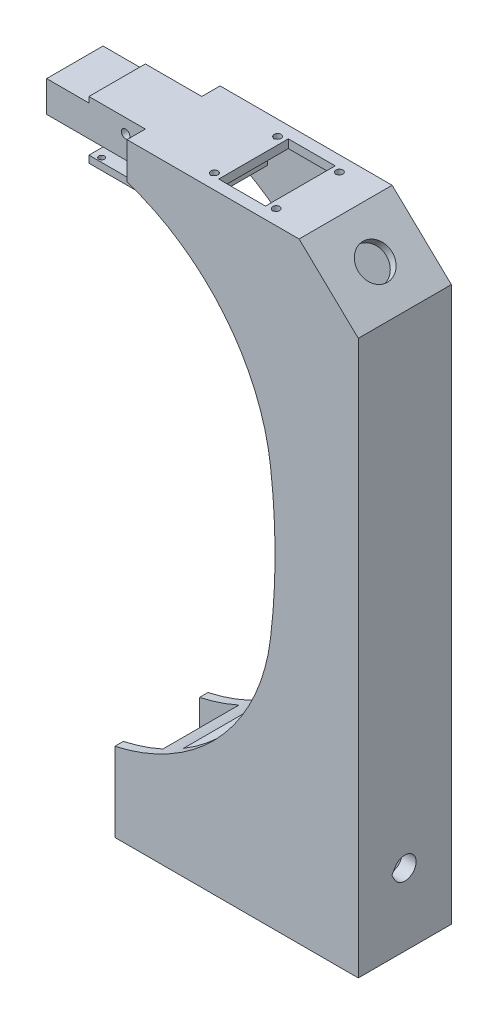
from build123d import *

# Parameters (mm, degrees)
EXTRUDE_6_DEPTH      = 33
CUT_EXTRUDE_START    = 3
CUT_EXTRUDE_2_DEPTH  = 27
EXTRUDE_START        = 6.5
SKETCH_7_W           = 35
SKETCH_7_H           = 13
EXTRUDE_7_DEPTH      = 20
EXTRUDE_START_2      = 1.5
SKETCH_11_W          = 17
SKETCH_11_H          = 2.5
EXTRUDE_15_DEPTH     = 30
CUT_EXTRUDE_START_2  = 180
CUT_EXTRUDE_3_DEPTH  = 10
SKETCH_13_R          = 1.5
CUT_EXTRUDE_4_DEPTH  = 30
SKETCH_14_W          = 15
SKETCH_14_H          = 2
CUT_EXTRUDE_5_DEPTH  = 30
EXTRUDE_START_3      = 11.5
SKETCH_15_W          = 67.299618531
SKETCH_15_H          = 10
EXTRUDE_16_DEPTH     = 10
CUT_EXTRUDE_START_3  = 17
CUT_EXTRUDE_7_DEPTH  = 75
CUT_EXTRUDE_START_4  = 13
CUT_EXTRUDE_9_DEPTH  = 5
SKETCH_20_W          = 16.6
SKETCH_20_H          = 24.7
CUT_EXTRUDE_10_DEPTH = 5
SKETCH_21_R          = 6
CUT_EXTRUDE_11_DEPTH = 5
SKETCH_22_W          = 51
SKETCH_22_H          = 47
CUT_EXTRUDE_12_DEPTH = 27


with BuildPart() as part:
    # Эскиз1 → Бобышка-Вытянуть6 (new body)
    with BuildSketch(Plane.XY):
        with BuildLine():
            Line((4.299618531, 175.402841826), (4.299618531, 188.402841826))
            Line((4.299618531, 188.402841826), (65.299618531, 188.402841826))
            Line((65.299618531, 188.402841826), (86.299618531, 168.402841826))
            Line((86.299618531, 168.402841826), (86.299619, 0))
            Line((86.299619, 0), (86.299619, -28))
            Line((86.299619, -28), (0, -28))
            Line((0, -28), (0, 0))
            ThreePointArc((0, 0), (37.229295141, 21.561020186), (55.173142182, 60.662380285))
            ThreePointArc((55.173142182, 60.662380285), (56.797307883, 87.162380285), (55.173142182, 113.662380285))
            ThreePointArc((55.173142182, 113.662380285), (38.726552267, 151.940422917), (4.299618531, 175.402841826))
        make_face()
    extrude(amount=EXTRUDE_6_DEPTH)

    # Эскиз5 → Вырез-Вытянуть2 (cut)
    with BuildSketch(Plane.XY.offset(CUT_EXTRUDE_START)):
        Polygon((24.099618531, 175.402841826), (4.299618531, 175.402841826), (4.299618531, 169.136823089), (-18.700381469, 169.136823089), (-18.700381469, -23.02337805), (14, -23.02337805), (14, 8.47662195), (81.178938205, 8.47662195), (81.178938205, 169.136823089), (64.099618531, 185.402841826), (24.099618531, 185.402841826), align=None)
    extrude(amount=CUT_EXTRUDE_2_DEPTH, mode=Mode.SUBTRACT)

    # Эскиз7 → Бобышка-Вытянуть7 (add)
    with BuildSketch(Plane.XY.offset(EXTRUDE_START)):
        with Locations((-13.200381469, 181.902841826)):
            Rectangle(SKETCH_7_W, SKETCH_7_H)
    extrude(amount=EXTRUDE_7_DEPTH)

    # Эскиз11 → Бобышка-Вытянуть15 (add)
    with BuildSketch(Plane.XY.offset(EXTRUDE_START_2)):
        with Locations((-2.200381469, 174.152841826)):
            Rectangle(SKETCH_11_W, SKETCH_11_H)
    extrude(amount=EXTRUDE_15_DEPTH)

    # Эскиз12 → Вырез-Вытянуть3 (cut)
    with BuildSketch(Plane(origin=(0, 0, 0), x_dir=(1, 0, 0), z_dir=(0, 1, 0)).offset(CUT_EXTRUDE_START_2)):
        with BuildLine():
            Line((-7.700381469, -31.154700538), (-7.200381469, -30.866025404))
            ThreePointArc((-7.200381469, -30.866025404), (-7.700381469, -29), (-8.200381469, -30.866025404))
            Line((-8.200381469, -30.866025404), (-7.700381469, -31.154700538))
        make_face()
        with BuildLine():
            Line((-7.700381469, -4.154700538), (-7.200381469, -3.866025404))
            ThreePointArc((-7.200381469, -3.866025404), (-7.700381469, -2), (-8.200381469, -3.866025404))
            Line((-8.200381469, -3.866025404), (-7.700381469, -4.154700538))
        make_face()
    extrude(amount=-CUT_EXTRUDE_3_DEPTH, mode=Mode.SUBTRACT)

    # Эскиз13 → Вырез-Вытянуть4 (cut)
    with BuildSketch(Plane.XY):
        with Locations((-2.700381469, 183.402841826)):
            Circle(SKETCH_13_R)
    extrude(amount=CUT_EXTRUDE_4_DEPTH, mode=Mode.SUBTRACT)

    # Эскиз14 → Вырез-Вытянуть5 (cut)
    with BuildSketch(Plane.XY):
        with Locations((-23.200381469, 187.402841826)):
            Rectangle(SKETCH_14_W, SKETCH_14_H)
    extrude(amount=CUT_EXTRUDE_5_DEPTH, mode=Mode.SUBTRACT)

    # Эскиз15 → Бобышка-Вытянуть16 (add)
    with BuildSketch(Plane.XY.offset(EXTRUDE_START_3)):
        with Locations((47.649809735, -2.5)):
            Rectangle(SKETCH_15_W, SKETCH_15_H)
    extrude(amount=EXTRUDE_16_DEPTH)

    # Эскиз17 → Вырез-Вытянуть7 (cut)
    with BuildSketch(Plane(origin=(0, 0, 0), x_dir=(0, 0, -1), z_dir=(1, 0, 0)).offset(CUT_EXTRUDE_START_3)):
        with BuildLine():
            Line((-21.118802154, -2.5), (-19.964101615, -0.5))
            ThreePointArc((-19.964101615, -0.5), (-12.5, -2.5), (-19.964101615, -4.5))
            Line((-19.964101615, -4.5), (-21.118802154, -2.5))
        make_face()
    extrude(amount=CUT_EXTRUDE_7_DEPTH, mode=Mode.SUBTRACT)

    # Эскиз18 → Вырез-Вытянуть9 (cut)
    with BuildSketch(Plane(origin=(0, 0, 0), x_dir=(0, 0, -1), z_dir=(1, 0, 0)).offset(CUT_EXTRUDE_START_4)):
        with BuildLine():
            Line((-18.809401077, -2.5), (-18.232050808, -1.5))
            ThreePointArc((-18.232050808, -1.5), (-14.5, -2.5), (-18.232050808, -3.5))
            Line((-18.232050808, -3.5), (-18.809401077, -2.5))
        make_face()
    extrude(amount=CUT_EXTRUDE_9_DEPTH, mode=Mode.SUBTRACT)

    # Эскиз20 → Вырез-Вытянуть10 (cut)
    with BuildSketch(Plane(origin=(0, 188.402841826, 0), x_dir=(1, 0, 0), z_dir=(0, 1, 0))):
        with Locations((40.95, -16.5)):
            Rectangle(SKETCH_20_W, SKETCH_20_H)
        with BuildLine():
            Line((30, -29.143375673), (30.625, -28.782531755))
            ThreePointArc((30.625, -28.782531755), (30, -26.45), (29.375, -28.782531755))
            Line((29.375, -28.782531755), (30, -29.143375673))
        make_face()
        with BuildLine():
            Line((30, -6.743375673), (30.625, -6.382531755))
            ThreePointArc((30.625, -6.382531755), (30, -4.05), (29.375, -6.382531755))
            Line((29.375, -6.382531755), (30, -6.743375673))
        make_face()
        with BuildLine():
            Line((51.9, -6.743375673), (52.525, -6.382531755))
            ThreePointArc((52.525, -6.382531755), (51.9, -4.05), (51.275, -6.382531755))
            Line((51.275, -6.382531755), (51.9, -6.743375673))
        make_face()
        with BuildLine():
            Line((51.9, -29.143375673), (52.525, -28.782531755))
            ThreePointArc((52.525, -28.782531755), (51.9, -26.45), (51.275, -28.782531755))
            Line((51.275, -28.782531755), (51.9, -29.143375673))
        make_face()
    extrude(amount=-CUT_EXTRUDE_10_DEPTH, mode=Mode.SUBTRACT)

    # Эскиз21 → Вырез-Вытянуть11 (cut)
    with BuildSketch(Plane(origin=(125.147492247, 131.404866859, 0), x_dir=(0, 0, -1), z_dir=(0.689655172, 0.724137931, 0))):
        with Locations((-16.5, 68.147063703)):
            Circle(SKETCH_21_R)
    extrude(amount=-CUT_EXTRUDE_11_DEPTH, mode=Mode.SUBTRACT)

    # Эскиз22 → Вырез-Вытянуть12 (cut)
    with BuildSketch(Plane.XY.offset(CUT_EXTRUDE_START)):
        with Locations((55.799619, -1.5)):
            Rectangle(SKETCH_22_W, SKETCH_22_H)
    extrude(amount=CUT_EXTRUDE_12_DEPTH, mode=Mode.SUBTRACT)


solid = part.part
